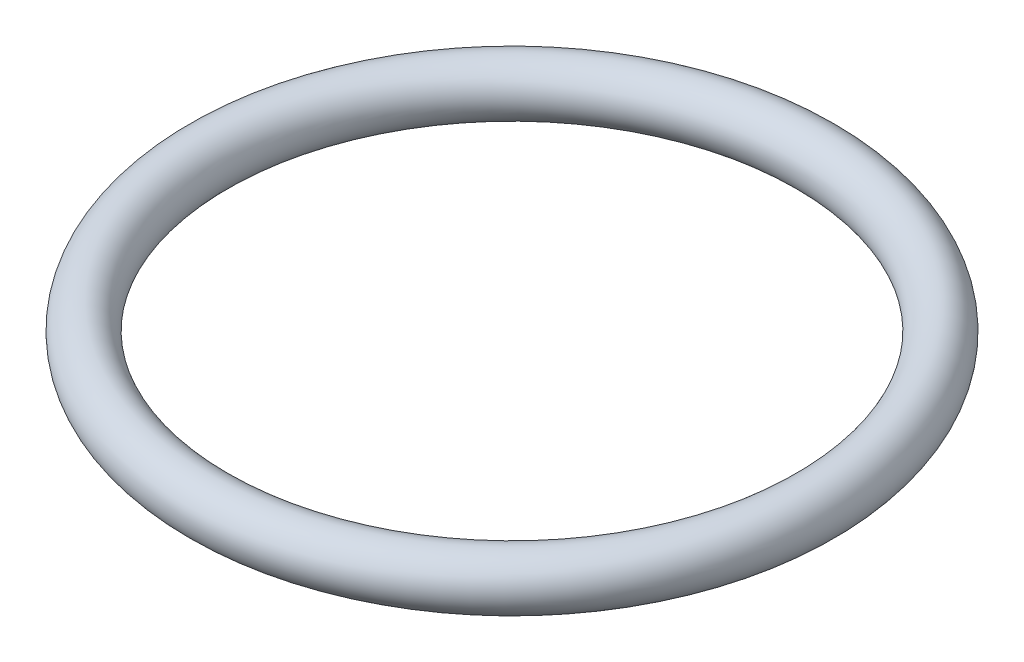
from build123d import *

# Parameters (mm, degrees)
SKETCH2_R = 2.5


with BuildPart() as part:
    # Sketch2 → Revolve1 (revolve)
    with BuildSketch(Plane(origin=(0, 0, 0), x_dir=(0, 0, -1), z_dir=(1, 0, 0))):
        with Locations((-28.5, 0)):
            Circle(SKETCH2_R)
    revolve(axis=Axis((0, 10.534454563, 0), (0, -1, 0)))


solid = part.part
